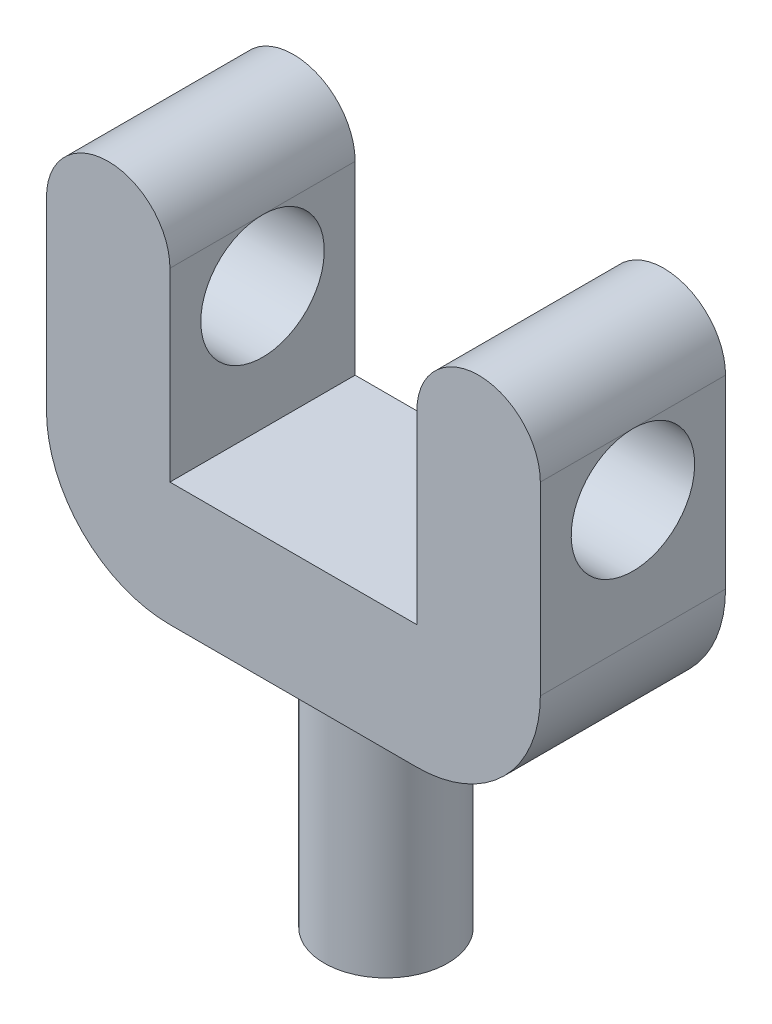
from build123d import *

# Parameters (mm, degrees)
BOSS_EXTRUDE1_DEPTH = 7.5
SKETCH3_R           = 5
BOSS_EXTRUDE2_DEPTH = 20
FILLET1_R           = 10
SKETCH2_R           = 5
CUT_EXTRUDE1_DEPTH  = 40


with BuildPart() as part:
    # Sketch1 → Boss-Extrude1 (new body, symmetric)
    with BuildSketch(Plane.XY):
        with BuildLine():
            Line((10, 5), (10, 20))
            ThreePointArc((10, 20), (15, 25), (20, 20))
            Line((20, 20), (20, -5))
            Line((20, -5), (-20, -5))
            Line((-20, -5), (-20, 20))
            ThreePointArc((-20, 20), (-15, 25), (-10, 20))
            Line((-10, 20), (-10, 5))
            Line((-10, 5), (10, 5))
        make_face()
    extrude(amount=BOSS_EXTRUDE1_DEPTH, both=True)

    # Sketch3 → Boss-Extrude2 (add)
    with BuildSketch(Plane.XZ.offset(5)):
        Circle(SKETCH3_R)
    extrude(amount=BOSS_EXTRUDE2_DEPTH)

    # Fillet1
    fillet1_edges = [part.edges().sort_by_distance(p)[0] for p in [
        (20, -5, 0),
        (-20, -5, 0),
    ]]
    fillet(fillet1_edges, radius=FILLET1_R)

    # Sketch2 → Cut-Extrude1 (cut)
    with BuildSketch(Plane(origin=(20, 0, 0), x_dir=(0, 0, -1), z_dir=(1, 0, 0))):
        with Locations((0, 15)):
            Circle(SKETCH2_R)
    extrude(amount=-CUT_EXTRUDE1_DEPTH, mode=Mode.SUBTRACT)


solid = part.part
